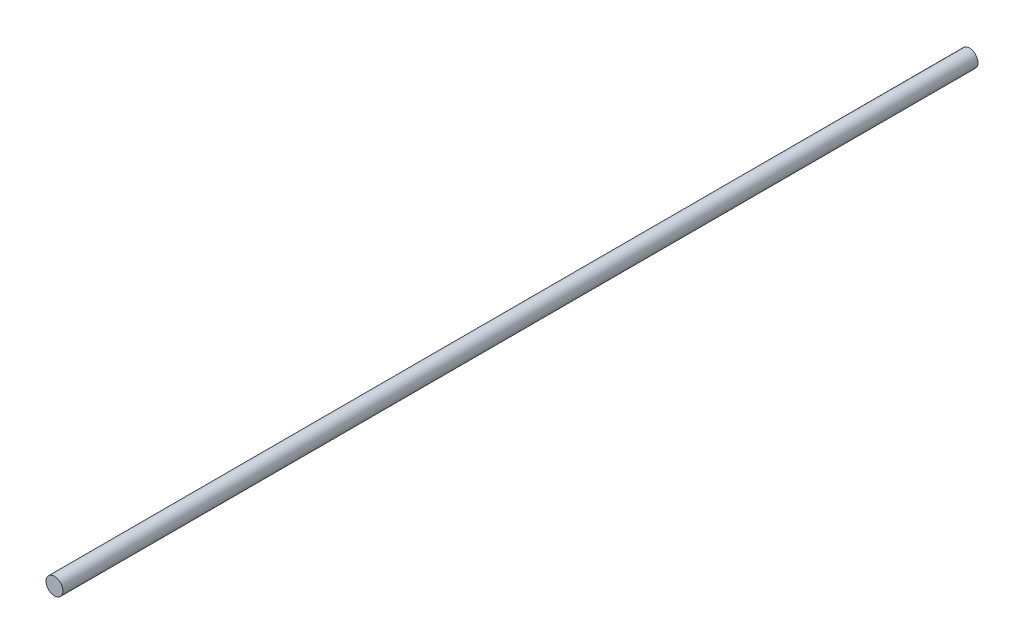
from build123d import *

# Parameters (mm, degrees)
EXTRUDE2_DEPTH      = 215.5
EXTRUDE2_DEPTH_BACK = 215.5
SKETCH1_R           = 4


with BuildPart() as part:
    # Sketch1 → Extrude2 (new, two sides: drawn at the far end of the back side and taken through both)
    with BuildSketch(Plane.XY.offset(-EXTRUDE2_DEPTH_BACK)):
        Circle(SKETCH1_R)
    extrude(amount=EXTRUDE2_DEPTH + EXTRUDE2_DEPTH_BACK)


solid = part.part
